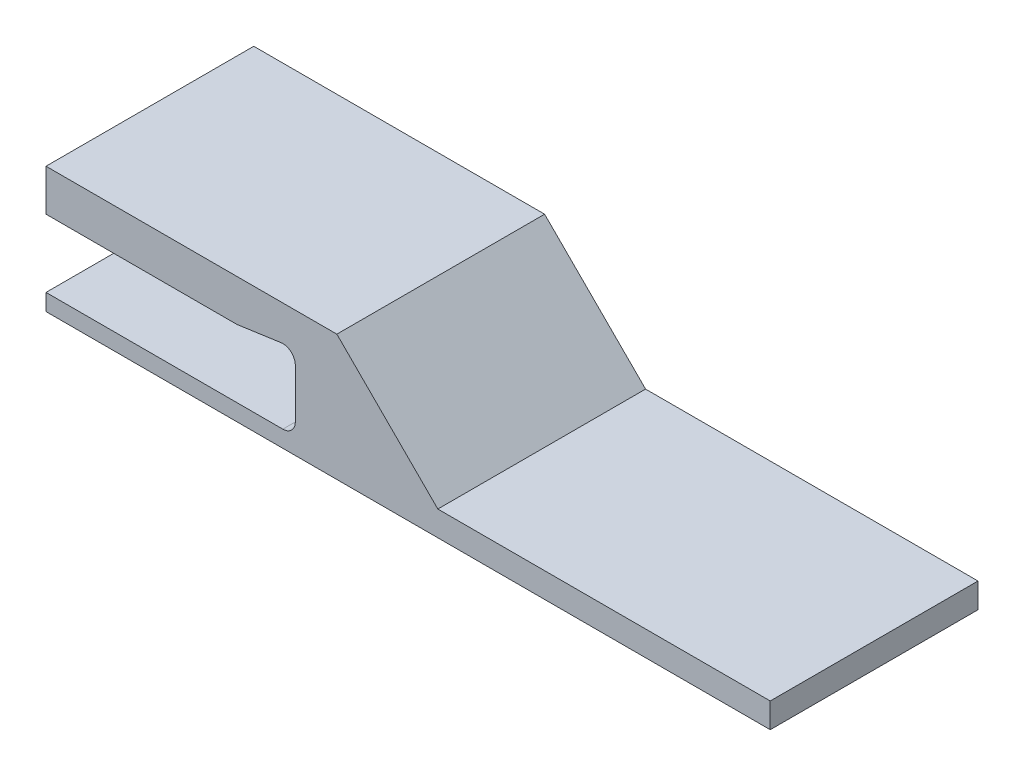
from build123d import *

# Parameters (mm, degrees)
BOSS_EXTRUDE1_DEPTH = 50


with BuildPart() as part:
    # Sketch1 → Boss-Extrude1 (new body)
    with BuildSketch(Plane.XY):
        with BuildLine():
            Line((0, 0), (0, 4))
            Line((0, 4), (57, 4))
            ThreePointArc((57, 4), (59.121320344, 4.878679656), (60, 7))
            Line((60, 7), (60, 18.840970938))
            ThreePointArc((60, 18.840970938), (58.965605224, 21.107332803), (56.575735931, 21.810819419))
            Line((56.575735931, 21.810819419), (46.211060633, 20.330151519))
            ThreePointArc((46.211060633, 20.330151519), (45.999463625, 20.307547374), (45.786796564, 20.3))
            Line((45.786796564, 20.3), (0, 20.3))
            Line((0, 20.3), (0, 30.3))
            Line((0, 30.3), (70, 30.3))
            Line((70, 30.3), (94.3, 6))
            Line((94.3, 6), (174.3, 6))
            Line((174.3, 6), (174.3, 0))
            Line((174.3, 0), (0, 0))
        make_face()
    extrude(amount=BOSS_EXTRUDE1_DEPTH)


solid = part.part
